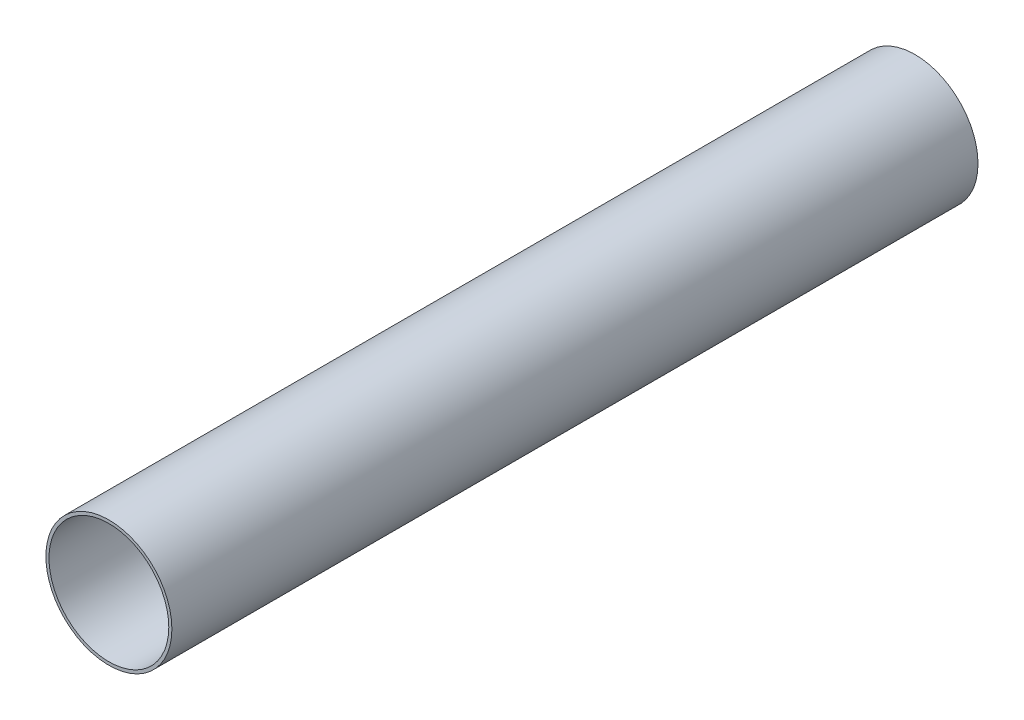
from build123d import *

# Parameters (mm, degrees)
ESBO_O1_R                = 50.8
ESBO_O1_R_2              = 48.3
RESSALTO_EXTRUS_O1_DEPTH = 650


with BuildPart() as part:
    # Esboço1 → Ressalto-extrusão1 (new body)
    with BuildSketch(Plane.XY):
        Circle(ESBO_O1_R)
        Circle(ESBO_O1_R_2, mode=Mode.SUBTRACT)
    extrude(amount=RESSALTO_EXTRUS_O1_DEPTH)


solid = part.part
